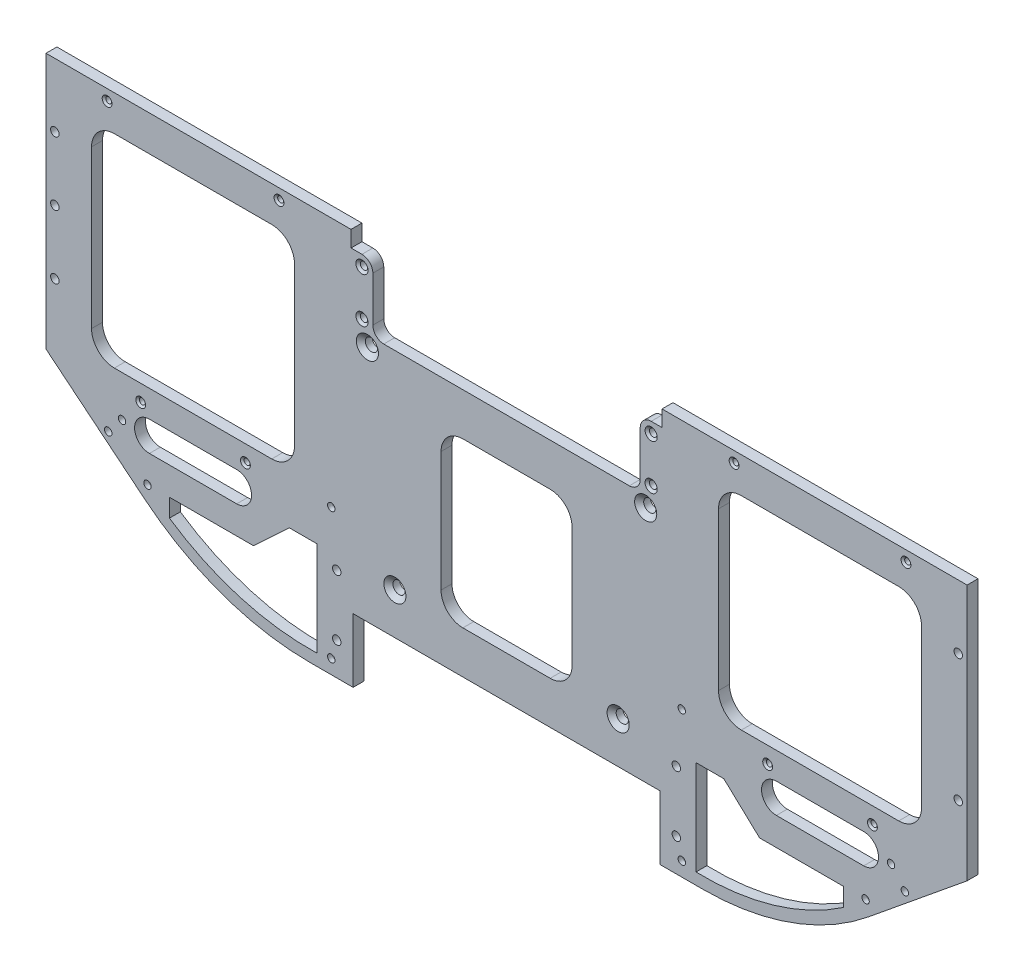
from build123d import *

# Parameters (mm, degrees)
BOSS_EXTRUDE1_DEPTH                                 = 6.35
CUT_EXTRUDE1_DEPTH                                  = 7.35
CSK_FOR_1_4_FLAT_HEAD_MACHINE_SCREW_100_D           = 7.14248
CSK_FOR_1_4_FLAT_HEAD_MACHINE_SCREW_100_DEPTH       = 6.35
CSK_FOR_1_4_FLAT_HEAD_MACHINE_SCREW_100_CSINK_D     = 12.8778
CSK_FOR_1_4_FLAT_HEAD_MACHINE_SCREW_100_CSINK_ANGLE = 100
CSK_FOR_4_FLAT_HEAD_MACHINE_SCREW_100_D             = 3.4544
CSK_FOR_4_FLAT_HEAD_MACHINE_SCREW_100_CSINK_D       = 5.715
CSK_FOR_4_FLAT_HEAD_MACHINE_SCREW_100_CSINK_ANGLE   = 100
CUT_EXTRUDE2_REACH                                  = 8.35
SKETCH7_W                                           = 178.5366
SKETCH7_H                                           = 37.1475
F_6_CLEARANCE_HOLE1_D                               = 4.3053
F_6_CLEARANCE_HOLE1_DEPTH                           = 6.35
F_6_PLASTIC_INSERT_AT_2_COUNT                       = 2
F_6_PLASTIC_INSERT_AT_2_PITCH                       = 112.229639339
F_6_PLASTIC_INSERT_AT_3_COUNT                       = 2
F_6_PLASTIC_INSERT_AT_3_PITCH                       = 114.9605422
F_6_PLASTIC_INSERT_AT_4_COUNT                       = 2
F_6_PLASTIC_INSERT_AT_4_PITCH                       = 313.747300742
F_6_PLASTIC_INSERT_AT_5_COUNT                       = 2
F_6_PLASTIC_INSERT_AT_5_PITCH                       = 312.75698938
F_6_PLASTIC_INSERT_AT_6_COUNT                       = 2
F_6_PLASTIC_INSERT_AT_6_PITCH                       = 417.83
F_6_CLEARANCE_HOLE2_D                               = 4.3053
CUT_EXTRUDE3_REACH                                  = 8.35
SKETCH55_W                                          = 12.7
SKETCH55_H                                          = 26.162975929
BOSS_EXTRUDE2_DEPTH                                 = 6.35
FILLET3_R                                           = 6.35
CSK_FOR_6_FLAT_HEAD_MACHINE_SCREW_100_D             = 4.3053
CSK_FOR_6_FLAT_HEAD_MACHINE_SCREW_100_CSINK_D       = 7.0866
CSK_FOR_6_FLAT_HEAD_MACHINE_SCREW_100_CSINK_ANGLE   = 100
SKETCH58_W                                          = 76.2
SKETCH58_H                                          = 95.25
CUT_EXTRUDE4_DEPTH                                  = 7.35
CUT_EXTRUDE5_DEPTH                                  = 7.35
CSK_FOR_8_FLAT_HEAD_MACHINE_SCREW_100_D             = 4.9149
CSK_FOR_8_FLAT_HEAD_MACHINE_SCREW_100_DEPTH         = 6.35
CSK_FOR_8_FLAT_HEAD_MACHINE_SCREW_100_CSINK_D       = 8.4328
CSK_FOR_8_FLAT_HEAD_MACHINE_SCREW_100_CSINK_ANGLE   = 100
FILLET4_R                                           = 12.7
CSK_FOR_6_FLAT_HEAD_MACHINE_SCREW_2_D               = 4.3053
CSK_FOR_6_FLAT_HEAD_MACHINE_SCREW_2_DEPTH           = 6.35
CSK_FOR_6_FLAT_HEAD_MACHINE_SCREW_2_CSINK_D         = 7.0866
CSK_FOR_6_FLAT_HEAD_MACHINE_SCREW_2_CSINK_ANGLE     = 100


with BuildPart() as part:
    # Sketch1 → Boss-Extrude1 (new body)
    with BuildSketch(Plane.XY):
        with BuildLine():
            Line((-296.70375, -233.3625), (-68.10375, -233.3625))
            ThreePointArc((-68.10375, -233.3625), (-16.943813494, -224.518833531), (28.278571633, -199.014217805))
            Line((28.278571633, -199.014217805), (95.09125, -144.4625))
            ThreePointArc((95.09125, -144.4625), (116.399773511, -117.921148224), (131.28625, -87.3125))
            Line((131.28625, -87.3125), (131.28625, 23.8125))
            Line((131.28625, 23.8125), (85.56625, 23.8125))
            Line((85.56625, 23.8125), (85.56625, -3.175))
            Line((85.56625, -3.175), (-131.60375, -3.175))
            Line((-131.60375, -3.175), (-131.60375, 20.5105))
            Line((-131.60375, 20.5105), (-233.20375, 20.5105))
            Line((-233.20375, 20.5105), (-233.20375, -3.175))
            Line((-233.20375, -3.175), (-450.37375, -3.175))
            Line((-450.37375, -3.175), (-450.37375, -20.955))
            Line((-450.37375, -20.955), (-496.09375, -20.955))
            Line((-496.09375, -20.955), (-496.09375, -87.3125))
            ThreePointArc((-496.09375, -87.3125), (-481.207273511, -117.921148224), (-459.89875, -144.4625))
            Line((-459.89875, -144.4625), (-393.086071633, -199.014217805))
            ThreePointArc((-393.086071633, -199.014217805), (-347.863686506, -224.518833531), (-296.70375, -233.3625))
        make_face()
    extrude(amount=BOSS_EXTRUDE1_DEPTH)

    # Sketch2 → Cut-Extrude1 (cut, through all)
    with BuildSketch(Plane.XY.offset(6.35)):
        with BuildLine():
            Line((-423.8625, -37.078640371), (-423.8625, -128.656359629))
            ThreePointArc((-423.8625, -128.656359629), (-419.976937445, -138.036937445), (-410.596359629, -141.9225))
            Line((-410.596359629, -141.9225), (-319.018640371, -141.9225))
            ThreePointArc((-319.018640371, -141.9225), (-309.638062555, -138.036937445), (-305.7525, -128.656359629))
            Line((-305.7525, -128.656359629), (-305.7525, -37.078640371))
            ThreePointArc((-305.7525, -37.078640371), (-309.638062555, -27.698062555), (-319.018640371, -23.8125))
            Line((-319.018640371, -23.8125), (-410.596359629, -23.8125))
            ThreePointArc((-410.596359629, -23.8125), (-419.976937445, -27.698062555), (-423.8625, -37.078640371))
        make_face()
        with BuildLine():
            Line((-292.63975, -171.533323999), (-292.63975, -226.638323184))
            ThreePointArc((-292.63975, -226.638323184), (-337.571759927, -220.847335922), (-378.554315308, -201.537980571))
            Line((-378.554315308, -201.537980571), (-378.554315308, -190.97625))
            Line((-378.554315308, -190.97625), (-329.636065959, -190.97625))
            Line((-329.636065959, -190.97625), (-308.800033111, -171.533323999))
            Line((-308.800033111, -171.533323999), (-292.63975, -171.533323999))
        make_face()
        with BuildLine():
            Line((-339.407500187, -174.752000205), (-390.207500187, -174.752000205))
            ThreePointArc((-390.207500187, -174.752000205), (-398.843500187, -166.116000205), (-390.207500187, -157.480000205))
            Line((-390.207500187, -157.480000205), (-339.407500187, -157.480000205))
            ThreePointArc((-339.407500187, -157.480000205), (-330.771500187, -166.116000205), (-339.407500187, -174.752000205))
        make_face()
        with BuildLine():
            Line((-25.399999813, -174.752000205), (25.400000187, -174.752000205))
            ThreePointArc((25.400000187, -174.752000205), (34.036000187, -166.116000205), (25.400000187, -157.480000205))
            Line((25.400000187, -157.480000205), (-25.399999813, -157.480000205))
            ThreePointArc((-25.399999813, -157.480000205), (-34.035999813, -166.116000205), (-25.399999813, -174.752000205))
        make_face()
        with BuildLine():
            Line((13.746815308, -201.537980571), (13.746815308, -190.97625))
            Line((13.746815308, -190.97625), (-35.171434041, -190.97625))
            Line((-35.171434041, -190.97625), (-56.007466889, -171.533323999))
            Line((-56.007466889, -171.533323999), (-72.16775, -171.533323999))
            Line((-72.16775, -171.533323999), (-72.16775, -226.638323184))
            ThreePointArc((-72.16775, -226.638323184), (-27.235740073, -220.847335922), (13.746815308, -201.537980571))
        make_face()
        with BuildLine():
            Line((45.788859629, -141.9225), (-45.788859629, -141.9225))
            ThreePointArc((-45.788859629, -141.9225), (-55.169437445, -138.036937445), (-59.055, -128.656359629))
            Line((-59.055, -128.656359629), (-59.055, -37.078640371))
            ThreePointArc((-59.055, -37.078640371), (-55.169437445, -27.698062555), (-45.788859629, -23.8125))
            Line((-45.788859629, -23.8125), (45.788859629, -23.8125))
            ThreePointArc((45.788859629, -23.8125), (55.169437445, -27.698062555), (59.055, -37.078640371))
            Line((59.055, -37.078640371), (59.055, -128.656359629))
            ThreePointArc((59.055, -128.656359629), (55.169437445, -138.036937445), (45.788859629, -141.9225))
        make_face()
    extrude(amount=-CUT_EXTRUDE1_DEPTH, mode=Mode.SUBTRACT)

    # CSK for 1/4 Flat Head Machine Screw (100)1
    with Locations(Plane.XY.offset(6.35)):
        with Locations((-247.36425, -172.085), (-263.36625, -57.785), (-117.44325, -172.085), (-101.44125, -57.785)):
            CounterSinkHole(CSK_FOR_1_4_FLAT_HEAD_MACHINE_SCREW_100_D / 2, CSK_FOR_1_4_FLAT_HEAD_MACHINE_SCREW_100_CSINK_D / 2, depth=CSK_FOR_1_4_FLAT_HEAD_MACHINE_SCREW_100_DEPTH, counter_sink_angle=CSK_FOR_1_4_FLAT_HEAD_MACHINE_SCREW_100_CSINK_ANGLE)

    # CSK for #4 Flat Head Machine Screw (100)1 (through all)
    with Locations(Plane.XY.offset(6.35)):
        with Locations((-334.327500123, -151.530549932), (-395.287499843, -151.53054989), (-314.801250003, -9.525000088), (-414.813749771, -9.52500002), (30.479999876, -151.530549932), (-30.479999843, -151.53054989), (50.006249997, -9.525000088), (-50.006249771, -9.52500002)):
            CounterSinkHole(CSK_FOR_4_FLAT_HEAD_MACHINE_SCREW_100_D / 2, CSK_FOR_4_FLAT_HEAD_MACHINE_SCREW_100_CSINK_D / 2, counter_sink_angle=CSK_FOR_4_FLAT_HEAD_MACHINE_SCREW_100_CSINK_ANGLE)

    # Sketch7 → Cut-Extrude2 (cut, up to next)
    with BuildSketch(Plane.XY.offset(6.35), mode=Mode.PRIVATE) as cut_extrude2_sk1:
        with Locations((-182.40375, -214.78875)):
            Rectangle(SKETCH7_W, SKETCH7_H)
    cut_extrude2_tool1 = extrude(cut_extrude2_sk1.sketch, amount=-CUT_EXTRUDE2_REACH, mode=Mode.PRIVATE) & part.part
    add(cut_extrude2_tool1.solids().sort_by_distance((-182.40375, -214.78875, 6.35))[0], mode=Mode.SUBTRACT)

    # #6 Clearance Hole1
    with Locations(Plane(origin=(-452.317147347, -175.564262538, 0), x_dir=(-1, 0, 0), z_dir=(0, 0, -1))):
        with Locations((-60.998397348, -15.475487462), (-167.932397348, -49.543237462), (-167.932397348, 26.726952124), (-371.894397347, 26.726952124), (-371.894397347, -49.543237462), (-478.828397347, -15.475487462)):
            Hole(F_6_CLEARANCE_HOLE1_D / 2, depth=F_6_CLEARANCE_HOLE1_DEPTH)

    # Sketch51 → #6 Plastic Insert (revolve, cut)
    with BuildSketch(Plane(origin=(-391.31875, -191.03975, 0), x_dir=(0, 1, 0), z_dir=(1, 0, 0))):
        Polygon((0, 0), (0, 3.81), (2.5273, 3.81), (2.6543, 0), align=None)
    f_6_plastic_insert = revolve(axis=Axis((-391.31875, -191.03975, 110), (0, 0, -1)), mode=Mode.SUBTRACT)

    # #6 Plastic Insert at 2: #6 Plastic Insert ×2
    with Locations(*[Vector(0.952814253, -0.303553947, 0) * (i * F_6_PLASTIC_INSERT_AT_2_PITCH) for i in range(1, F_6_PLASTIC_INSERT_AT_2_COUNT)]):
        add(f_6_plastic_insert, mode=Mode.SUBTRACT)

    # #6 Plastic Insert at 3: #6 Plastic Insert ×2
    with Locations(*[Vector(0.930180025, 0.367103693, 0) * (i * F_6_PLASTIC_INSERT_AT_3_PITCH) for i in range(1, F_6_PLASTIC_INSERT_AT_3_COUNT)]):
        add(f_6_plastic_insert, mode=Mode.SUBTRACT)

    # #6 Plastic Insert at 4: #6 Plastic Insert ×2
    with Locations(*[Vector(0.990912111, 0.134510925, 0) * (i * F_6_PLASTIC_INSERT_AT_4_PITCH) for i in range(1, F_6_PLASTIC_INSERT_AT_4_COUNT)]):
        add(f_6_plastic_insert, mode=Mode.SUBTRACT)

    # #6 Plastic Insert at 5: #6 Plastic Insert ×2
    with Locations(*[Vector(0.994049727, -0.108927222, 0) * (i * F_6_PLASTIC_INSERT_AT_5_PITCH) for i in range(1, F_6_PLASTIC_INSERT_AT_5_COUNT)]):
        add(f_6_plastic_insert, mode=Mode.SUBTRACT)

    # #6 Plastic Insert at 6: #6 Plastic Insert ×2
    with Locations(*[(i * F_6_PLASTIC_INSERT_AT_6_PITCH, 0, 0) for i in range(1, F_6_PLASTIC_INSERT_AT_6_COUNT)]):
        add(f_6_plastic_insert, mode=Mode.SUBTRACT)

    # #6 Clearance Hole2 (through all)
    with Locations(Plane(origin=(0, 0, 0), x_dir=(-1, 0, 0), z_dir=(0, 0, -1))):
        with Locations((459.51775, -126.1745), (479.90125, -91.8845), (486.50525, -36.449), (-94.71025, -126.1745), (-121.95175, -83.6295), (-98.26625, 15.875)):
            Hole(F_6_CLEARANCE_HOLE2_D / 2)

    # Sketch54 → Cut-Extrude3 (cut, up to next)
    with BuildSketch(Plane.XY.offset(6.35), mode=Mode.PRIVATE) as cut_extrude3_sk1:
        Polygon((-272.89125, -38.735), (-260.19125, -38.735), (-260.19125, -51.435), (-104.61625, -51.435), (-104.61625, -38.735), (-91.91625, -38.735), (-91.91625, 22.098), (-272.89125, 22.098), align=None)
    cut_extrude3_tool1 = extrude(cut_extrude3_sk1.sketch, amount=-CUT_EXTRUDE3_REACH, mode=Mode.PRIVATE) & part.part
    add(cut_extrude3_tool1.solids().sort_by_distance((-182.40375, -13.912881, 6.35))[0], mode=Mode.SUBTRACT)

    # Sketch55 → Boss-Extrude2 (add, through all)
    with BuildSketch(Plane.XY.offset(6.35)):
        with Locations((-98.26625, -25.653512036)):
            Rectangle(SKETCH55_W, SKETCH55_H)
        with Locations((-266.54125, -25.653512036)):
            Rectangle(SKETCH55_W, SKETCH55_H)
    extrude(amount=-BOSS_EXTRUDE2_DEPTH)

    # Fillet3
    fillet3_edges = [part.edges().sort_by_distance(p)[0] for p in [
        (-104.61625, -51.435, 3.175),
        (-260.19125, -51.435, 3.175),
        (-104.61625, -12.572024071, 3.175),
        (-260.19125, -12.572024071, 3.175),
    ]]
    fillet(fillet3_edges, radius=FILLET3_R)

    # CSK for _6 Flat Head Machine Screw _100 (through all)
    with Locations(Plane.XY.offset(6.35)):
        with Locations((-266.54125, -18.922024071), (-98.26625, -18.922024071), (-98.26625, -45.180737964), (-266.54125, -45.180737964)):
            CounterSinkHole(CSK_FOR_6_FLAT_HEAD_MACHINE_SCREW_100_D / 2, CSK_FOR_6_FLAT_HEAD_MACHINE_SCREW_100_CSINK_D / 2, counter_sink_angle=CSK_FOR_6_FLAT_HEAD_MACHINE_SCREW_100_CSINK_ANGLE)

    # Sketch58 → Cut-Extrude4 (cut, through all)
    with BuildSketch(Plane.XY.offset(6.35)):
        with Locations((-182.40375, -123.825)):
            Rectangle(SKETCH58_W, SKETCH58_H)
    extrude(amount=-CUT_EXTRUDE4_DEPTH, mode=Mode.SUBTRACT)

    # Sketch60 → Cut-Extrude5 (cut, through all)
    with BuildSketch(Plane.XY.offset(6.35)):
        with BuildLine():
            Line((85.56625, 23.8125), (85.56625, -152.239543591))
            Line((85.56625, -152.239543591), (95.09125, -144.4625))
            ThreePointArc((95.09125, -144.4625), (116.399773511, -117.921148224), (131.28625, -87.3125))
            Line((131.28625, -87.3125), (131.28625, 23.8125))
            Line((131.28625, 23.8125), (85.56625, 23.8125))
        make_face()
        with BuildLine():
            Line((-450.37375, -20.955), (-496.09375, -20.955))
            Line((-496.09375, -20.955), (-496.09375, -87.3125))
            ThreePointArc((-496.09375, -87.3125), (-481.207273511, -117.921148224), (-459.89875, -144.4625))
            Line((-459.89875, -144.4625), (-450.37375, -152.239543591))
            Line((-450.37375, -152.239543591), (-450.37375, -20.955))
        make_face()
    extrude(amount=-CUT_EXTRUDE5_DEPTH, mode=Mode.SUBTRACT)

    # CSK for #8 Flat Head Machine Screw (100)2
    with Locations(Plane(origin=(0, 0, 0), x_dir=(-1, 0, 0), z_dir=(0, 0, -1))):
        with Locations((281.19705, -214.3125), (281.19705, -179.105836743), (445.23025, -77.214725701), (445.23025, -40.194862851), (445.23025, -114.234588552), (-80.42275, -114.234588552), (-80.42275, -40.194862851), (83.61045, -179.105836743), (83.61045, -214.3125)):
            CounterSinkHole(CSK_FOR_8_FLAT_HEAD_MACHINE_SCREW_100_D / 2, CSK_FOR_8_FLAT_HEAD_MACHINE_SCREW_100_CSINK_D / 2, depth=CSK_FOR_8_FLAT_HEAD_MACHINE_SCREW_100_DEPTH, counter_sink_angle=CSK_FOR_8_FLAT_HEAD_MACHINE_SCREW_100_CSINK_ANGLE)

    # Fillet4
    fillet4_edges = [part.edges().sort_by_distance(p)[0] for p in [
        (-220.50375, -171.45, 3.175),
        (-220.50375, -76.2, 3.175),
        (-144.30375, -76.2, 3.175),
        (-144.30375, -171.45, 3.175),
    ]]
    fillet(fillet4_edges, radius=FILLET4_R)

    # CSK for _6 Flat Head Machine Screw _ 2
    with Locations(Plane(origin=(0, 0, 0), x_dir=(-1, 0, 0), z_dir=(0, 0, -1))):
        with Locations((414.160403417, -175.658955234), (406.128271665, -165.821533849), (-41.318287119, -165.823323002), (-49.350418871, -175.660744388)):
            CounterSinkHole(CSK_FOR_6_FLAT_HEAD_MACHINE_SCREW_2_D / 2, CSK_FOR_6_FLAT_HEAD_MACHINE_SCREW_2_CSINK_D / 2, depth=CSK_FOR_6_FLAT_HEAD_MACHINE_SCREW_2_DEPTH, counter_sink_angle=CSK_FOR_6_FLAT_HEAD_MACHINE_SCREW_2_CSINK_ANGLE)


solid = part.part
